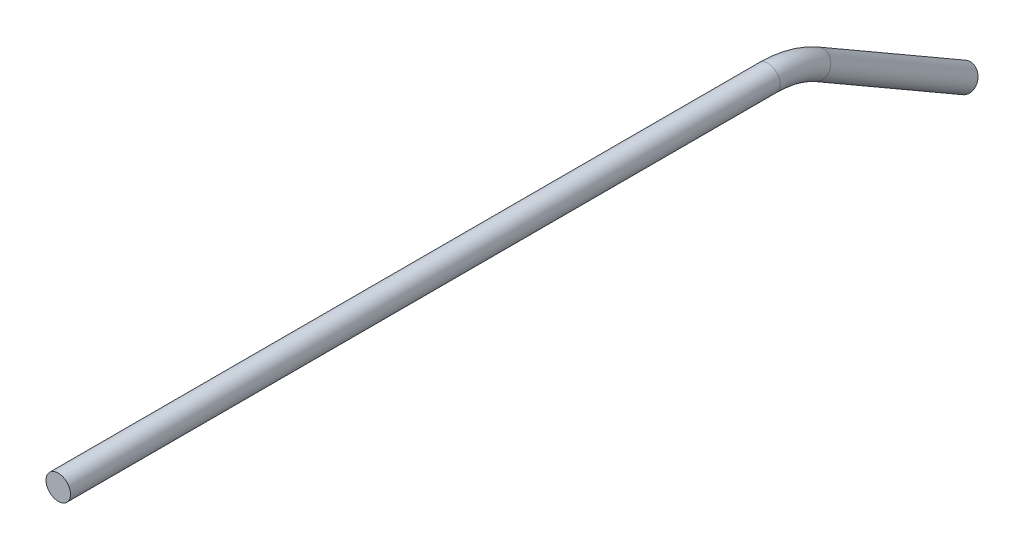
from build123d import *

# Parameters (mm, degrees)
SKETCH2_R = 3.175


with BuildPart() as part:
    # Sweep1: sweep along a path in Sketch4
    with BuildLine(Plane(origin=(0, 0, 0), x_dir=(0, 0, -1), z_dir=(1, 0, 0))) as sweep1_path:
        Line((0, 0), (183.694090512, 0))
        ThreePointArc((183.694090512, 0), (190.268094258, -0.865484012), (196.394090512, -3.402954744))
        Line((196.394090512, -3.402954744), (234.494090512, -25.4))
    # Sketch2 → Sweep1 (sweep)
    with BuildSketch(Plane.XY):
        Circle(SKETCH2_R)
    sweep(path=sweep1_path.line)


solid = part.part
